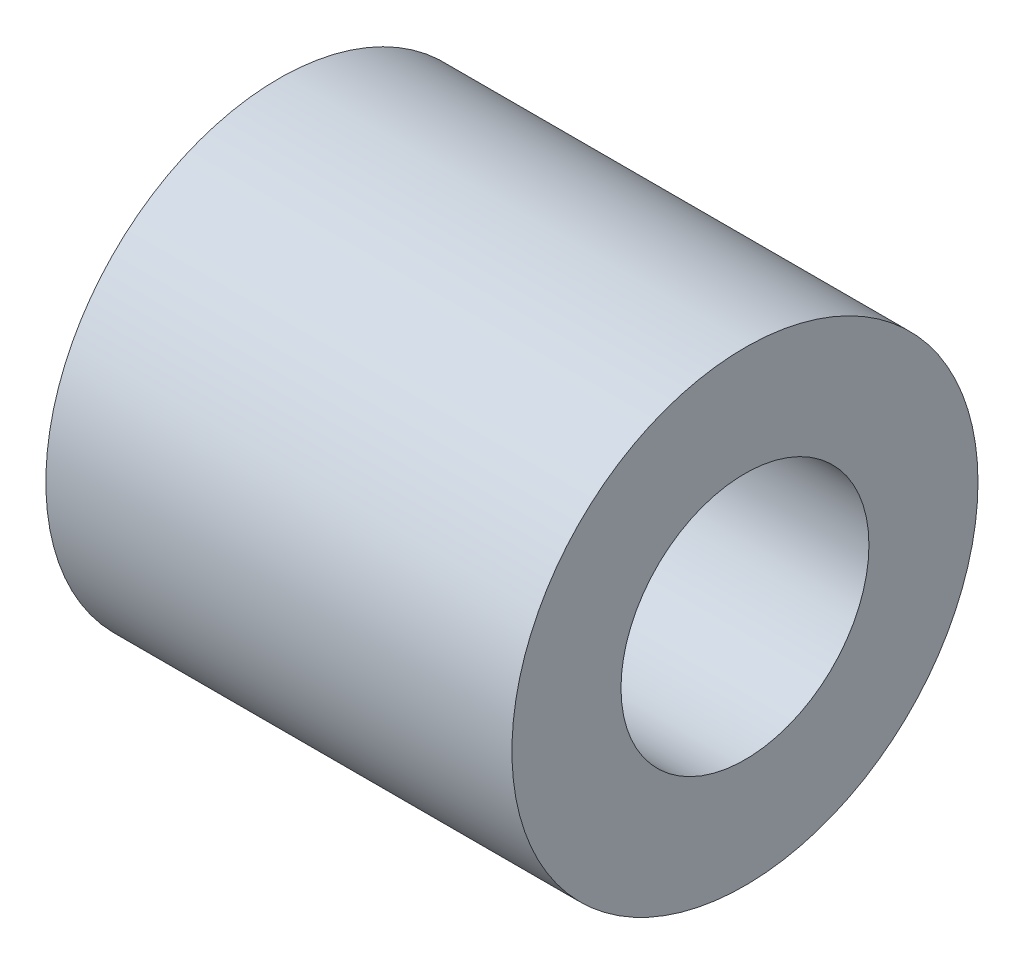
from build123d import *

# Parameters (mm, degrees)
SKETCH1_R           = 6.35
SKETCH1_R_2         = 3.3782
BOSS_EXTRUDE1_DEPTH = 12.7


with BuildPart() as part:
    # Sketch1 → Boss-Extrude1 (new body)
    with BuildSketch(Plane(origin=(0, 0, 0), x_dir=(0, 0, -1), z_dir=(1, 0, 0))):
        Circle(SKETCH1_R)
        Circle(SKETCH1_R_2, mode=Mode.SUBTRACT)
    extrude(amount=BOSS_EXTRUDE1_DEPTH)


solid = part.part
